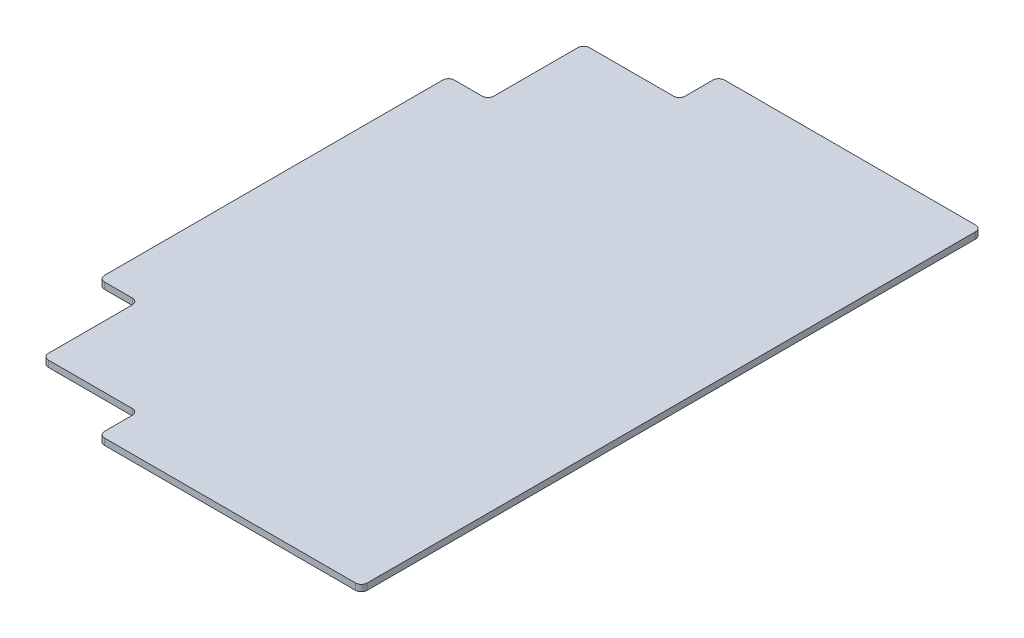
from build123d import *

# Parameters (mm, degrees)
SKETCH1_W           = 190.5
SKETCH1_H           = 304.8
BOSS_EXTRUDE1_DEPTH = 2.778125
SKETCH2_W           = 190.5
SKETCH2_H           = 17.78
CUT_EXTRUDE1_DEPTH  = 3.778125
SKETCH3_W           = 17.78
SKETCH3_H           = 269.24
CUT_EXTRUDE2_DEPTH  = 3.778125
CUT_EXTRUDE3_DEPTH  = 3.778125
FILLET1_R           = 2.54


with BuildPart() as part:
    # Sketch1 → Boss-Extrude1 (new body)
    with BuildSketch(Plane(origin=(0, 0, 0), x_dir=(1, 0, 0), z_dir=(0, 1, 0))):
        with Locations((95.25, 152.4)):
            Rectangle(SKETCH1_W, SKETCH1_H)
    extrude(amount=BOSS_EXTRUDE1_DEPTH)

    # Sketch2 → Cut-Extrude1 (cut, through all)
    with BuildSketch(Plane(origin=(0, 2.778125, 0), x_dir=(1, 0, 0), z_dir=(0, 1, 0))):
        with Locations((95.25, 8.89)):
            Rectangle(SKETCH2_W, SKETCH2_H)
        with Locations((95.25, 295.91)):
            Rectangle(SKETCH2_W, SKETCH2_H)
    extrude(amount=-CUT_EXTRUDE1_DEPTH, mode=Mode.SUBTRACT)

    # Sketch3 → Cut-Extrude2 (cut, through all)
    with BuildSketch(Plane(origin=(0, 2.778125, 0), x_dir=(1, 0, 0), z_dir=(0, 1, 0))):
        with Locations((8.89, 152.4)):
            Rectangle(SKETCH3_W, SKETCH3_H)
    extrude(amount=-CUT_EXTRUDE2_DEPTH, mode=Mode.SUBTRACT)

    # Sketch4 → Cut-Extrude3 (cut, through all)
    with BuildSketch(Plane(origin=(0, 2.778125, 0), x_dir=(1, 0, 0), z_dir=(0, 1, 0))):
        Polygon((17.78, 287.02), (76.454, 287.02), (76.454, 269.875), (34.925, 269.875), (34.925, 228.346), (17.78, 228.346), align=None)
        Polygon((17.78, 17.78), (76.454, 17.78), (76.454, 34.925), (34.925, 34.925), (34.925, 76.454), (17.78, 76.454), align=None)
    extrude(amount=-CUT_EXTRUDE3_DEPTH, mode=Mode.SUBTRACT)

    # Fillet1
    fillet1_edges = [part.edges().sort_by_distance(p)[0] for p in [
        (190.5, 1.3890625, -17.78),
        (190.5, 1.3890625, -287.02),
        (17.78, 1.3890625, -228.346),
        (76.454, 1.3890625, -287.02),
        (76.454, 1.3890625, -269.875),
        (34.925, 1.3890625, -269.875),
        (34.925, 1.3890625, -228.346),
        (17.78, 1.3890625, -76.454),
        (34.925, 1.3890625, -76.454),
        (34.925, 1.3890625, -34.925),
        (76.454, 1.3890625, -34.925),
        (76.454, 1.3890625, -17.78),
    ]]
    fillet(fillet1_edges, radius=FILLET1_R)


solid = part.part
